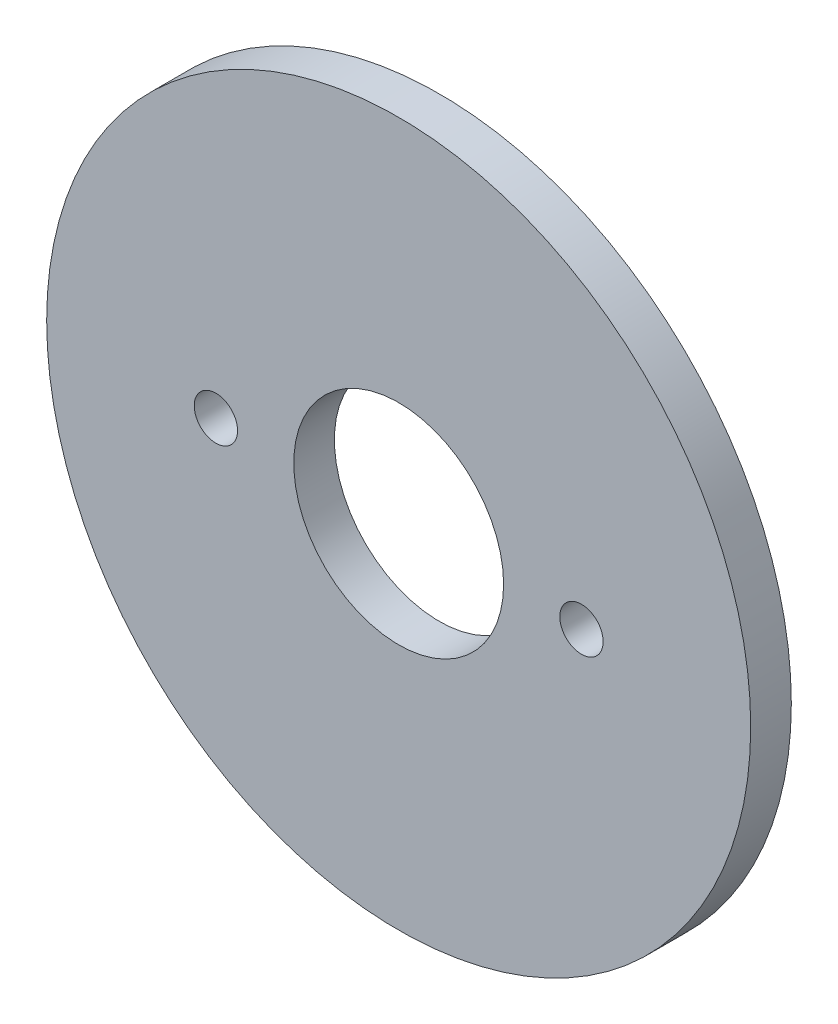
from build123d import *

# Parameters (mm, degrees)
ESBO_O1_R                = 26
ESBO_O1_R_2              = 7.75
ESBO_O1_R_3              = 1.6
RESSALTO_EXTRUS_O1_DEPTH = 1.5


with BuildPart() as part:
    # Esboço1 → Ressalto-extrusão1 (new body, symmetric)
    with BuildSketch(Plane.XY):
        Circle(ESBO_O1_R)
        Circle(ESBO_O1_R_2, mode=Mode.SUBTRACT)
        with Locations((-13.5, 0)):
            Circle(ESBO_O1_R_3, mode=Mode.SUBTRACT)
        with Locations((13.5, 0)):
            Circle(ESBO_O1_R_3, mode=Mode.SUBTRACT)
    extrude(amount=RESSALTO_EXTRUS_O1_DEPTH, both=True)


solid = part.part
